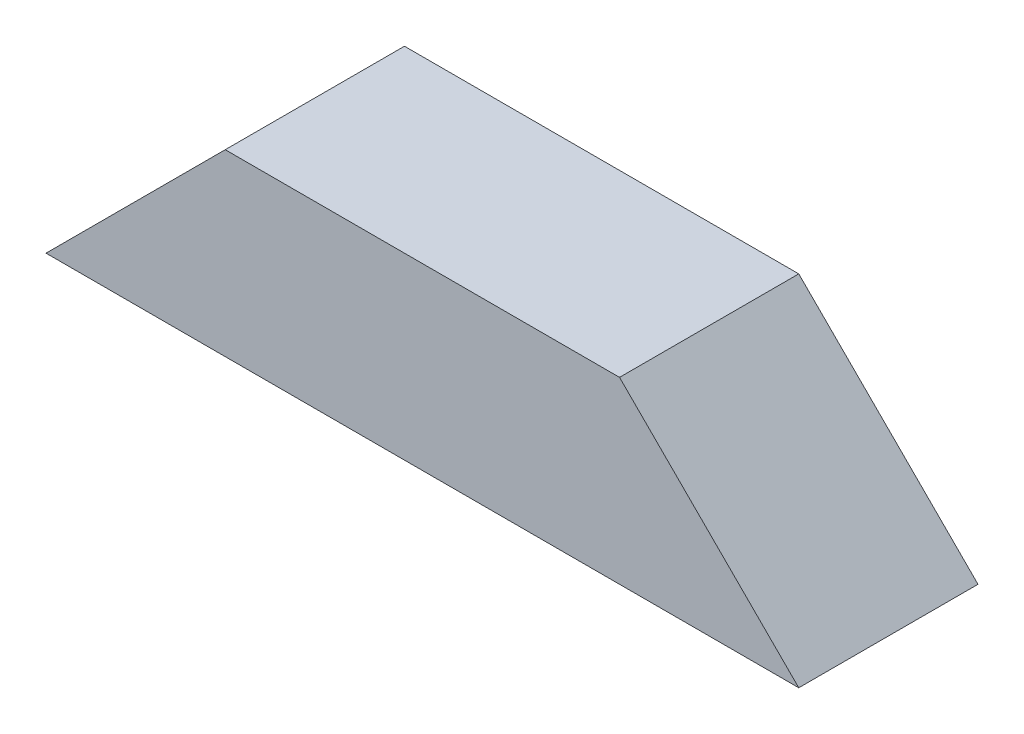
from build123d import *

# Parameters (mm, degrees)
EXTRUDE_1_DEPTH = 20


with BuildPart() as part:
    # 草图1 → 凸台-拉伸1 (new body)
    with BuildSketch(Plane.XY):
        Polygon((77.287034004, 99.844207638), (161.287067604, 99.844207638), (141.287067604, 119.844207638), (97.287034004, 119.844207638), align=None)
    extrude(amount=EXTRUDE_1_DEPTH)


solid = part.part
